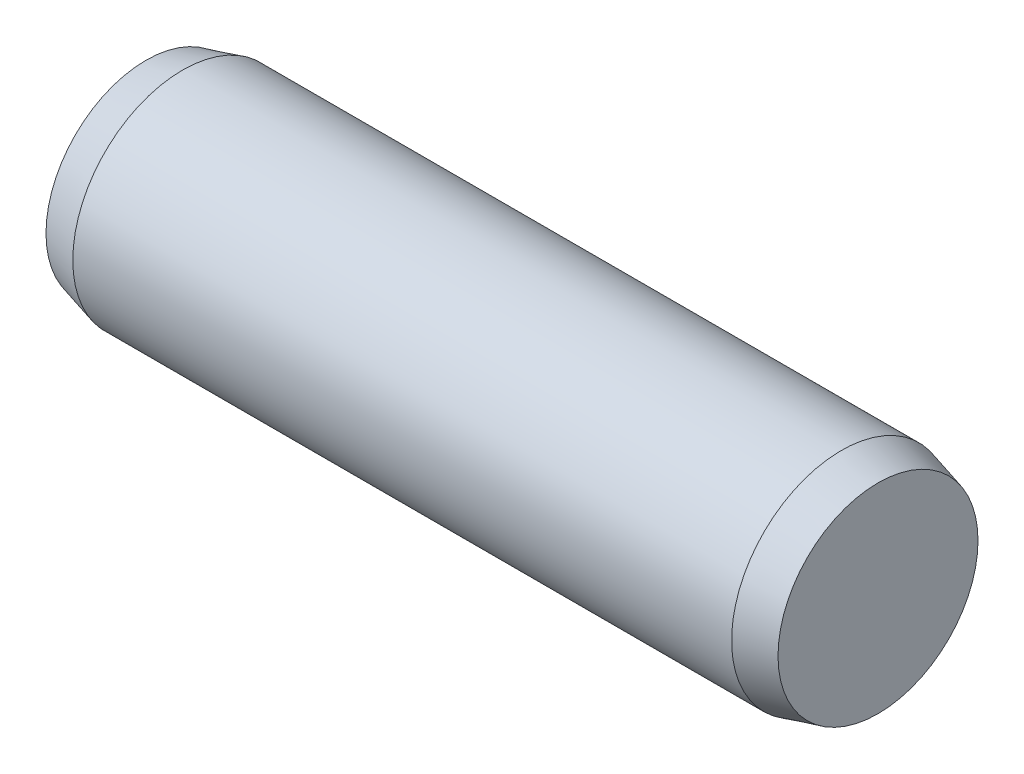
from build123d import *

# Parameters (mm, degrees)
SKETCH2_R           = 1.5
EXTRUDE1_DEPTH      = 4.5
EXTRUDE1_DEPTH_BACK = 4.5
SKETCH3_R           = 1.5
EXTRUDE2_DEPTH      = 0.5
EXTRUDE2_TAPER      = 15
SKETCH4_R           = 1.5
EXTRUDE3_DEPTH      = 0.5
EXTRUDE3_TAPER      = 15


with BuildPart() as part:
    # Sketch2 → Extrude1 (new body, two sides)
    with BuildSketch(Plane(origin=(0, 0, 0), x_dir=(0, 0, -1), z_dir=(1, 0, 0))) as extrude1_sk:
        Circle(SKETCH2_R)
    extrude(amount=EXTRUDE1_DEPTH)
    extrude(extrude1_sk.sketch, amount=-EXTRUDE1_DEPTH_BACK)

    # Sketch3 → Extrude2 (add)
    with BuildSketch(Plane(origin=(4.5, 0, 0), x_dir=(0, 0, -1), z_dir=(1, 0, 0))):
        Circle(SKETCH3_R)
    extrude(amount=EXTRUDE2_DEPTH, taper=EXTRUDE2_TAPER)

    # Sketch4 → Extrude3 (add)
    with BuildSketch(Plane.ZY.offset(4.5)):
        Circle(SKETCH4_R)
    extrude(amount=EXTRUDE3_DEPTH, taper=EXTRUDE3_TAPER)


solid = part.part
